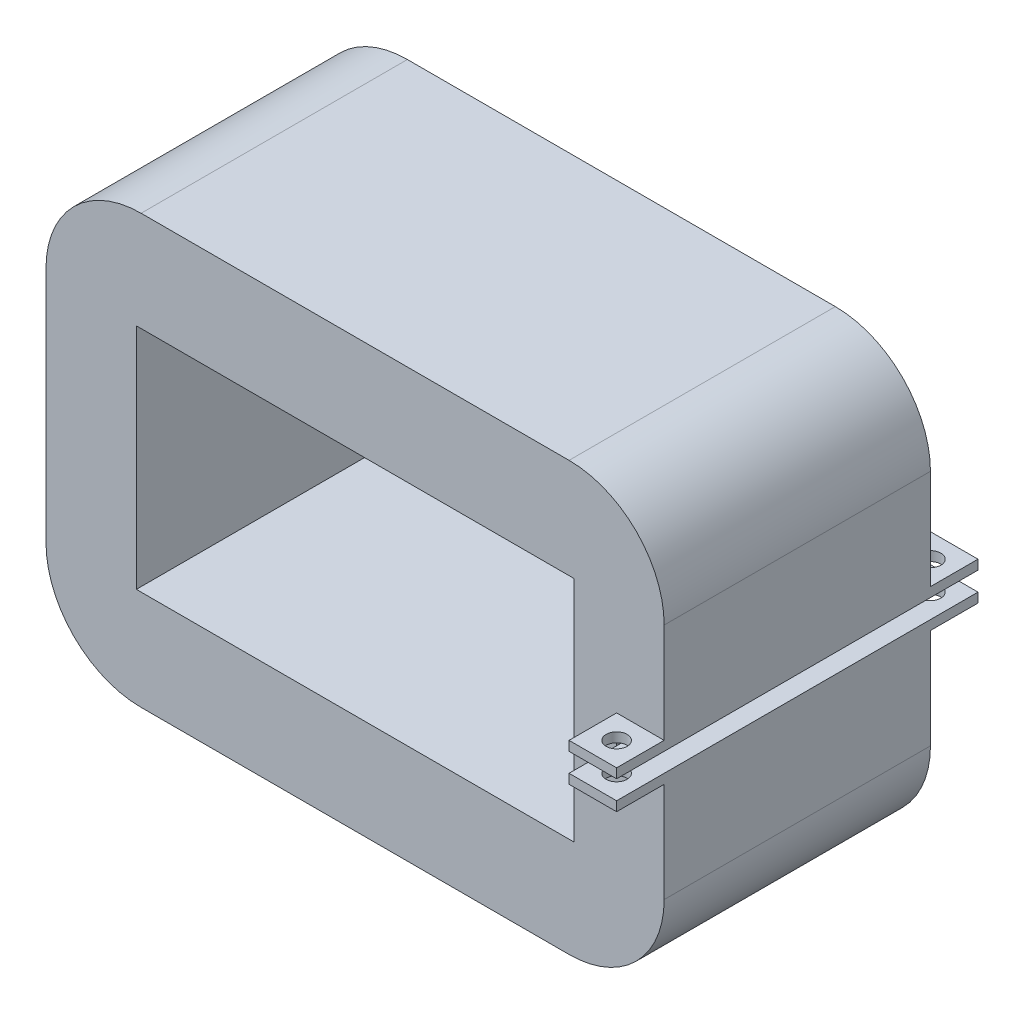
from build123d import *

# Parameters (mm, degrees)
SKETCH_1_W               = 65
SKETCH_1_H               = 45
EXTRUDE_1_DEPTH          = 28
SKETCH_2_W               = 46
SKETCH_2_H               = 24
CUT_EXTRUDE_1_DEPTH      = 39
FILLET_1_R               = 10
FILLET_2_R               = 10
FILLET_3_R               = 10
FILLET_4_R               = 10
SKETCH_9_W               = 5
SKETCH_9_H               = 34.070621565
CUT_EXTRUDE_2_DEPTH      = 1
CUT_EXTRUDE_2_DEPTH_BACK = 1
SKETCH_10_W              = 5
SKETCH_10_H              = 1
EXTRUDE_5_DEPTH          = 5
SKETCH_12_R              = 1.1
CUT_EXTRUDE_3_DEPTH      = 5
PATTERN_LINEAR_1_COUNT   = 2
PATTERN_LINEAR_1_PITCH   = 33
PATTERN_LINEAR_2_COUNT   = 2
PATTERN_LINEAR_2_PITCH   = 33


with BuildPart() as part:
    # 草圖1 → 填料-伸長1 (new body)
    with BuildSketch(Plane.XY):
        with Locations((-27.434655272, 0)):
            Rectangle(SKETCH_1_W, SKETCH_1_H)
    extrude(amount=EXTRUDE_1_DEPTH)

    # 草圖2 → 除料-伸長1 (cut)
    with BuildSketch(Plane.XY):
        with Locations((-27.434655272, 0)):
            Rectangle(SKETCH_2_W, SKETCH_2_H)
    extrude(amount=CUT_EXTRUDE_1_DEPTH, mode=Mode.SUBTRACT)

    # 圓角1
    fillet_1_edges = [part.edges().sort_by_distance(p)[0] for p in [
        (-59.934655272, -22.5, 14),
    ]]
    fillet(fillet_1_edges, radius=FILLET_1_R)

    # 圓角2
    fillet_2_edges = [part.edges().sort_by_distance(p)[0] for p in [
        (-59.934655272, 22.5, 14),
    ]]
    fillet(fillet_2_edges, radius=FILLET_2_R)

    # 圓角3
    fillet_3_edges = [part.edges().sort_by_distance(p)[0] for p in [
        (5.065344728, 22.5, 14),
    ]]
    fillet(fillet_3_edges, radius=FILLET_3_R)

    # 圓角4
    fillet_4_edges = [part.edges().sort_by_distance(p)[0] for p in [
        (5.065344728, -22.5, 14),
    ]]
    fillet(fillet_4_edges, radius=FILLET_4_R)

    # 草圖9 → 除料-伸長2 (cut, two sides)
    with BuildSketch(Plane(origin=(0, 0, 0), x_dir=(1, 0, 0), z_dir=(0, 1, 0))) as cut_extrude_2_sk:
        with Locations((2.565344728, -13.723230761)):
            Rectangle(SKETCH_9_W, SKETCH_9_H)
    extrude(amount=CUT_EXTRUDE_2_DEPTH, mode=Mode.SUBTRACT)
    extrude(cut_extrude_2_sk.sketch, amount=-CUT_EXTRUDE_2_DEPTH_BACK, mode=Mode.SUBTRACT)

    # 草圖10 → 填料-伸長5 (add)
    with BuildSketch(Plane.XY):
        with Locations((2.565344728, -1.5)):
            Rectangle(SKETCH_10_W, SKETCH_10_H)
        with Locations((2.565344728, 1.5)):
            Rectangle(SKETCH_10_W, SKETCH_10_H)
    extrude_5 = extrude(amount=-EXTRUDE_5_DEPTH)

    # 草圖12 → 除料-伸長3 (cut)
    with BuildSketch(Plane(origin=(0, -2, 0), x_dir=(-1, 0, 0), z_dir=(0, -1, 0))):
        with Locations((-2.565344728, 2.5)):
            Circle(SKETCH_12_R)
    cut_extrude_3 = extrude(amount=-CUT_EXTRUDE_3_DEPTH, mode=Mode.SUBTRACT)

    # 直線複製排列1: 填料-伸長5 ×2
    with Locations(*[(0, 0, i * PATTERN_LINEAR_1_PITCH) for i in range(1, PATTERN_LINEAR_1_COUNT)]):
        add(extrude_5)

    # 直線複製排列2: 除料-伸長3 ×2
    with Locations(*[(0, 0, i * PATTERN_LINEAR_2_PITCH) for i in range(1, PATTERN_LINEAR_2_COUNT)]):
        add(cut_extrude_3, mode=Mode.SUBTRACT)


solid = part.part
